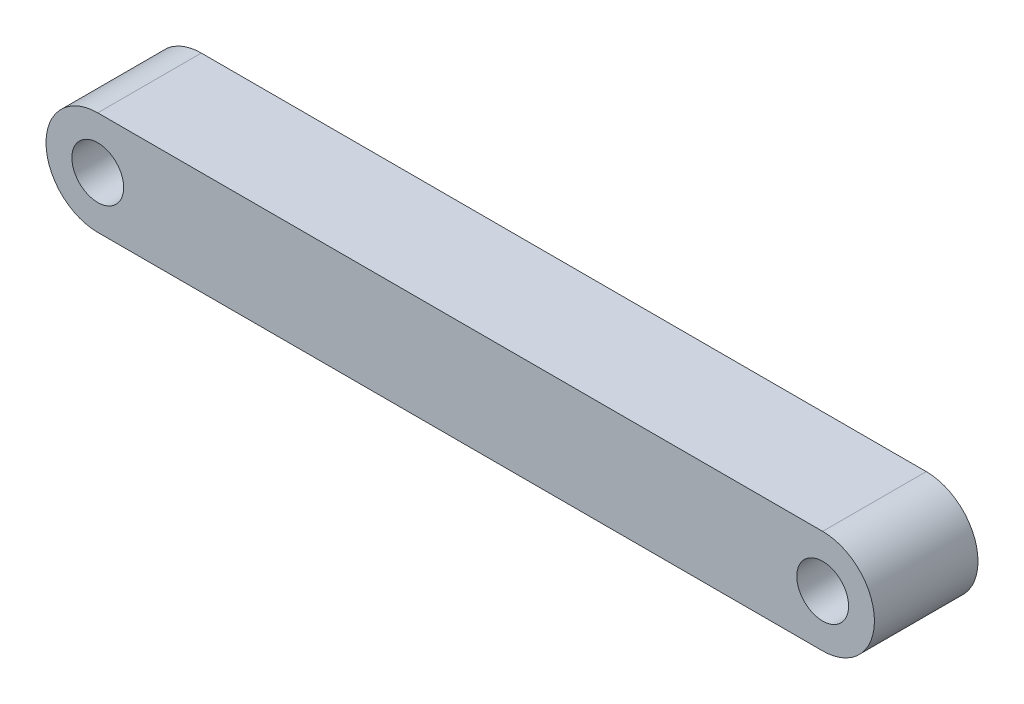
from build123d import *

# Parameters (mm, degrees)
SKETCH1_R           = 2.5
BOSS_EXTRUDE1_DEPTH = 10


with BuildPart() as part:
    # Sketch1 → Boss-Extrude1 (new body)
    with BuildSketch(Plane.XY):
        with BuildLine():
            Line((0, 5), (-70, 5))
            ThreePointArc((-70, 5), (-75, 0), (-70, -5))
            Line((-70, -5), (0, -5))
            ThreePointArc((0, -5), (5, 0), (0, 5))
        make_face()
        Circle(SKETCH1_R, mode=Mode.SUBTRACT)
        with Locations((-70, 0)):
            Circle(SKETCH1_R, mode=Mode.SUBTRACT)
    extrude(amount=BOSS_EXTRUDE1_DEPTH)


solid = part.part
